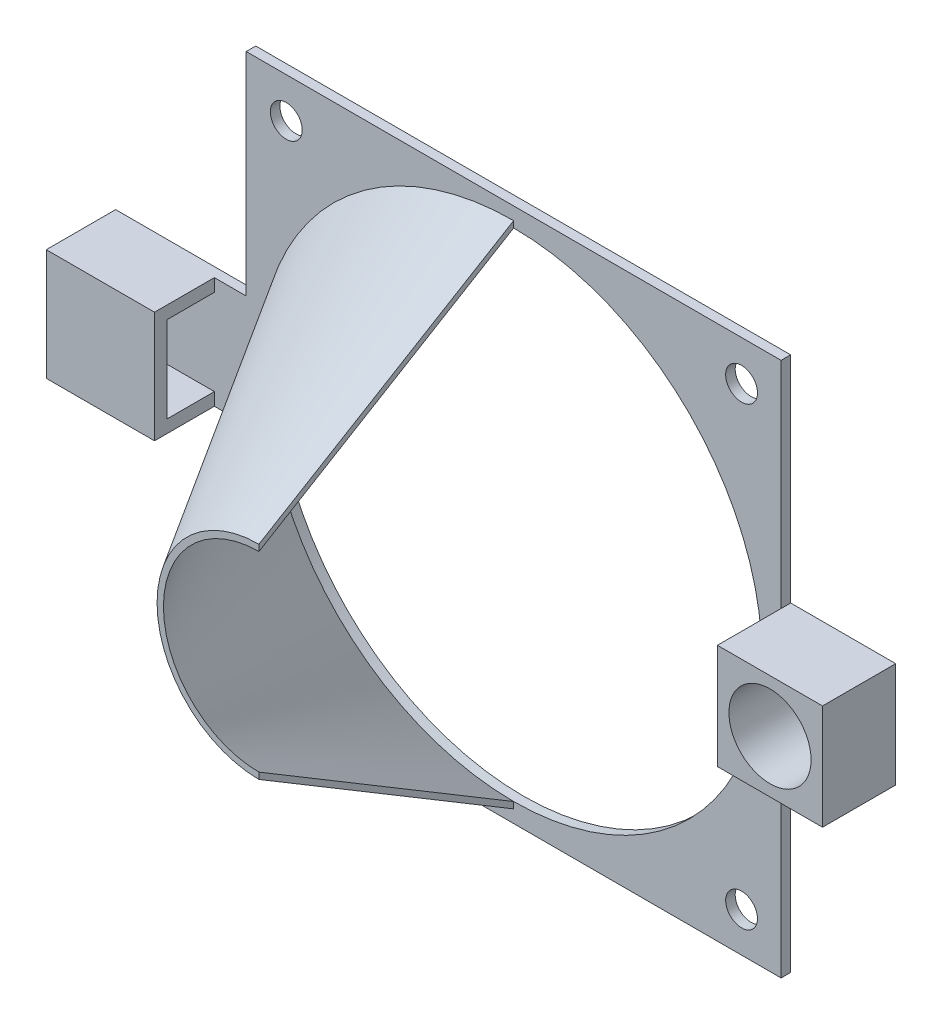
from build123d import *

# Parameters (mm, degrees)
CROQUIS1_W              = 84
CROQUIS1_H              = 84
CROQUIS1_R              = 39
CROQUIS1_R_2            = 2.5
SALIENTE_EXTRUIR1_DEPTH = 1.5
REVOLUCI_N2_ANGLE       = 180
SALIENTE_EXTRUIR2_DEPTH = 20
SALIENTE_EXTRUIR3_DEPTH = 15
CROQUIS8_W              = 10.9
CROQUIS8_H              = 17.5
CROQUIS8_R              = 3.6
SALIENTE_EXTRUIR4_DEPTH = 2
SALIENTE_EXTRUIR5_DEPTH = 16.5
CROQUIS10_W             = 16.5
CROQUIS10_H             = 16.5
CROQUIS10_R             = 6.45
SALIENTE_EXTRUIR6_DEPTH = 10


with BuildPart() as part:
    # Croquis1 → Saliente-Extruir1 (new body)
    with BuildSketch(Plane.XY):
        with Locations((-61.319838057, -7.506072874)):
            Rectangle(CROQUIS1_W, CROQUIS1_H)
        with Locations((-61.319838057, -7.506072874)):
            Circle(CROQUIS1_R, mode=Mode.SUBTRACT)
        with Locations((-97.028730507, 28.202819575)):
            Circle(CROQUIS1_R_2, mode=Mode.SUBTRACT)
        with Locations((-25.528730507, 28.202819575)):
            Circle(CROQUIS1_R_2, mode=Mode.SUBTRACT)
        with Locations((-25.528730507, -43.297180425)):
            Circle(CROQUIS1_R_2, mode=Mode.SUBTRACT)
        with Locations((-97.028730507, -43.297180425)):
            Circle(CROQUIS1_R_2, mode=Mode.SUBTRACT)
    extrude(amount=SALIENTE_EXTRUIR1_DEPTH)

    # Croquis4 → Revolución2 (revolve)
    with BuildSketch(Plane(origin=(-61.319838057, -49.506072874, 1.5), x_dir=(0, 0, -1), z_dir=(1, 0, 0))):
        Polygon((-40, 27), (0, 3), (0, 2), (-40, 26), align=None)
    revolve(axis=Axis((-61.319838057, -7.506072874, 1.5), (0, 0, -1)), revolution_arc=REVOLUCI_N2_ANGLE)

    # Croquis6 → Saliente-Extruir2 (add)
    with BuildSketch(Plane.ZY.offset(103.319838057)):
        Polygon((0, -7.506072874), (0, -16.256072874), (1.5, -16.256072874), (1.5, 1.243927126), (0, 1.243927126), align=None)
    extrude(amount=SALIENTE_EXTRUIR2_DEPTH)

    # Croquis7 → Saliente-Extruir3 (add)
    with BuildSketch(Plane.ZY.offset(123.319838057)):
        Polygon((10.9, 1.243927126), (1.5, 1.243927126), (1.5, -0.756072874), (8.9, -0.756072874), (8.9, -14.256072874), (1.5, -14.256072874), (1.5, -16.256072874), (10.9, -16.256072874), align=None)
    extrude(amount=-SALIENTE_EXTRUIR3_DEPTH)

    # Croquis8 → Saliente-Extruir4 (add)
    with BuildSketch(Plane.ZY.offset(123.319838057)):
        with Locations((5.45, -7.506072874)):
            Rectangle(CROQUIS8_W, CROQUIS8_H)
        with Locations((5.45, -7.506072874)):
            Circle(CROQUIS8_R, mode=Mode.SUBTRACT)
    extrude(amount=SALIENTE_EXTRUIR4_DEPTH)

    # Croquis9 → Saliente-Extruir5 (add)
    with BuildSketch(Plane(origin=(-19.319838057, 0, 0), x_dir=(0, 0, -1), z_dir=(1, 0, 0))):
        Polygon((0, -7.506072874), (0, 0.743927126), (-1.5, 0.743927126), (-1.5, -15.756072874), (0, -15.756072874), align=None)
    extrude(amount=SALIENTE_EXTRUIR5_DEPTH)

    # Croquis10 → Saliente-Extruir6 (add)
    with BuildSketch(Plane.XY.offset(1.5)):
        with Locations((-11.069838057, -7.506072874)):
            Rectangle(CROQUIS10_W, CROQUIS10_H)
        with Locations((-11.069838057, -7.506072874)):
            Circle(CROQUIS10_R, mode=Mode.SUBTRACT)
    extrude(amount=SALIENTE_EXTRUIR6_DEPTH)


solid = part.part
